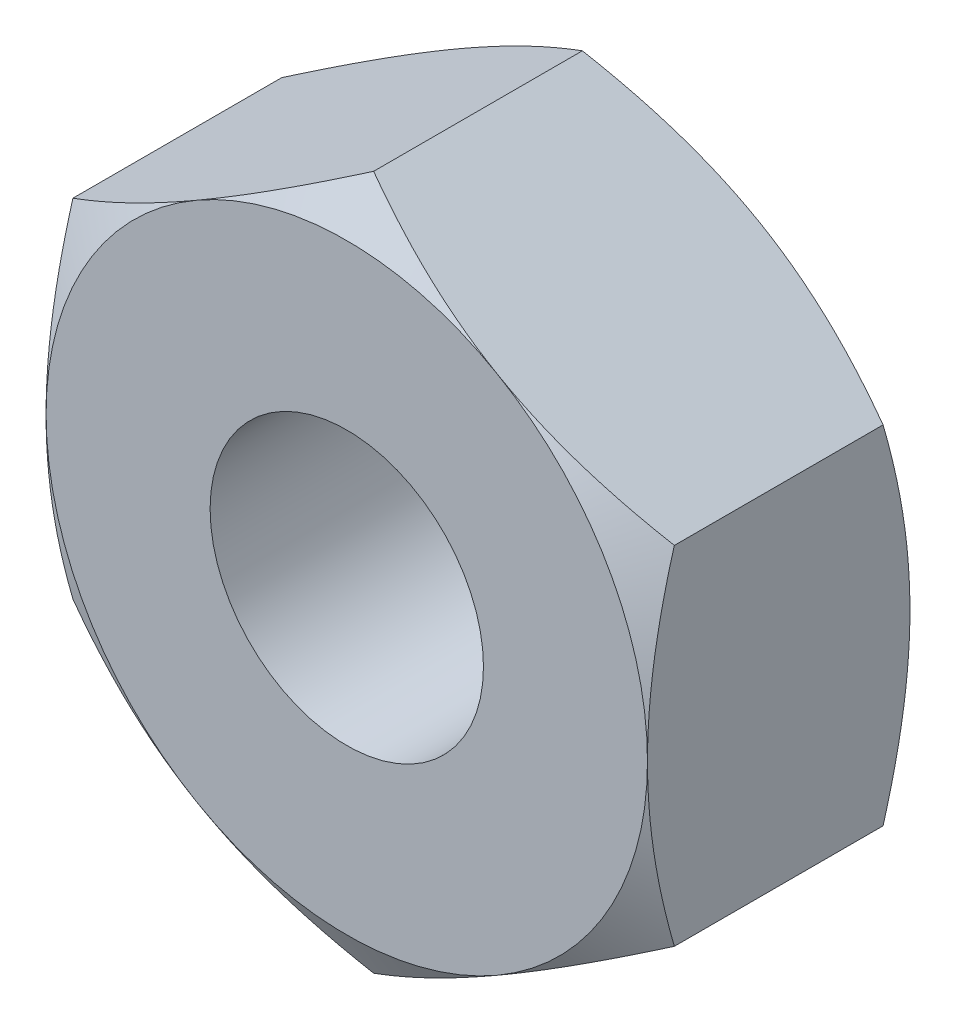
from build123d import *

# Parameters (mm, degrees)
SKETCH2_R           = 1.25
BOSS_EXTRUDE1_DEPTH = 1.2


with BuildPart() as part:
    # Sketch2 → Boss-Extrude1 (new body, symmetric)
    with BuildSketch(Plane.XY):
        Polygon((2.75, 1.58771324), (2.75, -1.58771324), (0, -3.175426481), (-2.75, -1.58771324), (-2.75, 1.58771324), (0, 3.175426481), align=None)
        Circle(SKETCH2_R, mode=Mode.SUBTRACT)
    extrude(amount=BOSS_EXTRUDE1_DEPTH, both=True)

    # Sketch4 → Cut-Revolve2 (revolve, cut)
    with BuildSketch(Plane(origin=(0, 0, 0), x_dir=(0, 0, -1), z_dir=(1, 0, 0))):
        Polygon((1.2, 2.75), (1.2, 4.328660734), (0.2885598, 4.328660734), align=None)
    cut_revolve2 = revolve(axis=Axis((0, 0, 2.99453507), (0, 0, -1)), mode=Mode.SUBTRACT)

    # Mirror1: Cut-Revolve2 across plane
    add(cut_revolve2.mirror(Plane.XY), mode=Mode.SUBTRACT)


solid = part.part
